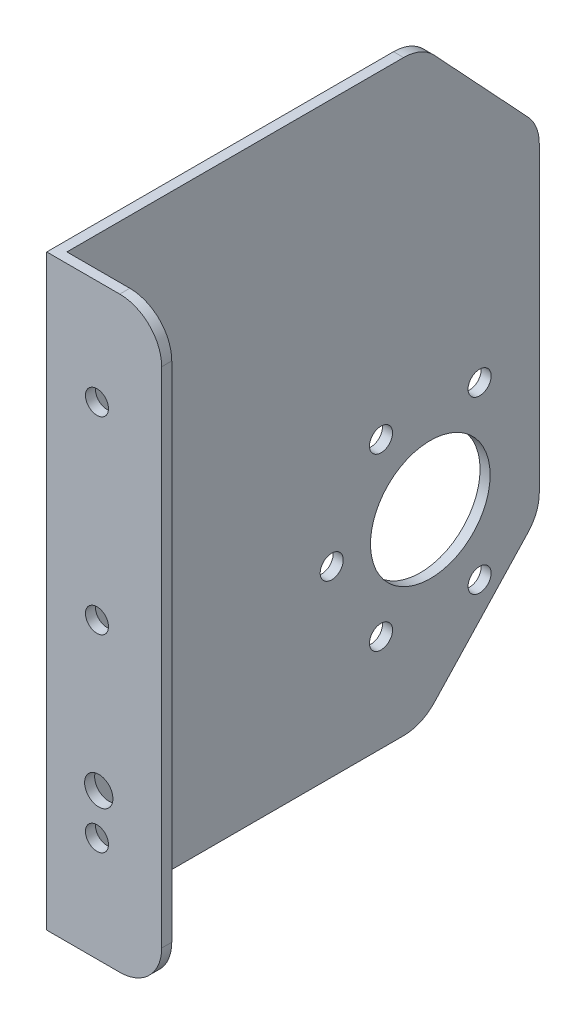
from build123d import *

# Parameters (mm, degrees)
SKETCH1_W           = 115
SKETCH1_H           = 140
BOSS_EXTRUDE1_DEPTH = 2.4
CUT_EXTRUDE1_DEPTH  = 3.4
FILLET1_R           = 10
SKETCH3_W           = 2.4
SKETCH3_H           = 140
BOSS_EXTRUDE2_DEPTH = 25
FILLET2_R           = 10
SKETCH4_R           = 2.75
CUT_EXTRUDE2_DEPTH  = 116
SKETCH5_R           = 14.26
SKETCH5_R_2         = 2.75
CUT_EXTRUDE3_DEPTH  = 3.4
SKETCH6_R           = 3.375
CUT_EXTRUDE4_DEPTH  = 116


with BuildPart() as part:
    # Sketch1 → Boss-Extrude1 (new body)
    with BuildSketch(Plane(origin=(0, 0, 0), x_dir=(0, 0, -1), z_dir=(1, 0, 0))):
        with Locations((57.5, -70)):
            Rectangle(SKETCH1_W, SKETCH1_H)
    extrude(amount=BOSS_EXTRUDE1_DEPTH)

    # Sketch2 → Cut-Extrude1 (cut, through all)
    with BuildSketch(Plane(origin=(2.4, 0, 0), x_dir=(0, 0, -1), z_dir=(1, 0, 0))):
        Polygon((87, 0), (115, -30), (142.616199658, -32.505405645), (142.616199658, 14.875556406), align=None)
        Polygon((115, -110), (87, -140), (87, -152.661109726), (136.310004643, -152.661109726), align=None)
    extrude(amount=-CUT_EXTRUDE1_DEPTH, mode=Mode.SUBTRACT)

    # Fillet1
    fillet1_edges = [part.edges().sort_by_distance(p)[0] for p in [
        (1.2, 0, -87),
        (1.2, -30, -115),
        (1.2, -110, -115),
        (1.2, -140, -87),
    ]]
    fillet(fillet1_edges, radius=FILLET1_R)

    # Sketch3 → Boss-Extrude2 (add)
    with BuildSketch(Plane(origin=(2.4, 0, 0), x_dir=(0, 0, -1), z_dir=(1, 0, 0))):
        with Locations((1.2, -70)):
            Rectangle(SKETCH3_W, SKETCH3_H)
    extrude(amount=BOSS_EXTRUDE2_DEPTH)

    # Fillet2
    fillet2_edges = [part.edges().sort_by_distance(p)[0] for p in [
        (27.4, -140, -1.2),
        (27.4, 0, -1.2),
    ]]
    fillet(fillet2_edges, radius=FILLET2_R)

    # Sketch4 → Cut-Extrude2 (cut, through all)
    with BuildSketch(Plane.XY):
        with Locations((11.974983581, -70)):
            Circle(SKETCH4_R)
        with Locations((11.974983581, -25)):
            Circle(SKETCH4_R)
        with Locations((11.974983581, -115)):
            Circle(SKETCH4_R)
    extrude(amount=-CUT_EXTRUDE2_DEPTH, mode=Mode.SUBTRACT)

    # Sketch5 → Cut-Extrude3 (cut, through all)
    with BuildSketch(Plane(origin=(2.4, 0, 0), x_dir=(0, 0, -1), z_dir=(1, 0, 0))):
        with Locations((89.027947804, -96.494029199)):
            Circle(SKETCH5_R)
        with Locations((77.277947804, -76.14243221)):
            Circle(SKETCH5_R_2)
        with Locations((100.777947804, -76.14243221)):
            Circle(SKETCH5_R_2)
        with Locations((100.777947804, -116.845626188)):
            Circle(SKETCH5_R_2)
        with Locations((77.277947804, -116.845626188)):
            Circle(SKETCH5_R_2)
        with Locations((65.527947804, -96.494029199)):
            Circle(SKETCH5_R_2)
    extrude(amount=-CUT_EXTRUDE3_DEPTH, mode=Mode.SUBTRACT)

    # Sketch6 → Cut-Extrude4 (cut, through all)
    with BuildSketch(Plane.XY):
        with Locations((12.4, -105)):
            Circle(SKETCH6_R)
    extrude(amount=-CUT_EXTRUDE4_DEPTH, mode=Mode.SUBTRACT)


solid = part.part
